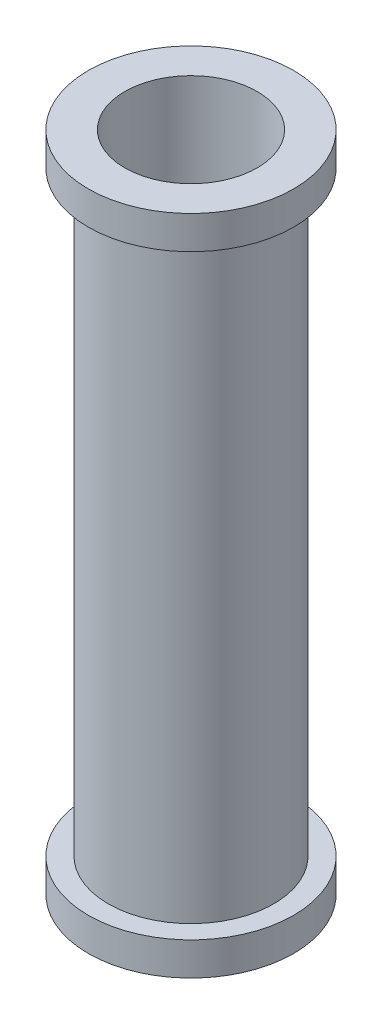
from build123d import *

# Parameters (mm, degrees)
SKETCH3_R   = 0.25
SKETCH3_R_2 = 0.2
SKETCH6_R   = 0.31
SKETCH6_R_2 = 0.21


with BuildPart() as part:
    # Sweep-Thin1: sweep along a path in Sketch1
    with BuildLine(Plane.XY) as sweep_thin1_path:
        Line((0, 0), (0, 1))
    # Sketch3 → Sweep-Thin1 (sweep)
    with BuildSketch(Plane(origin=(0, 0, 0), x_dir=(1, 0, 0), z_dir=(0, 1, 0))):
        Circle(SKETCH3_R)
        Circle(SKETCH3_R_2, mode=Mode.SUBTRACT)
    sweep(path=sweep_thin1_path.line)

    # Sweep-Thin2: sweep along a path in Sketch5
    with BuildLine(Plane.XY) as sweep_thin2_path:
        Line((0, 0), (0, 0.1))
    # Sketch6 → Sweep-Thin2 (sweep)
    with BuildSketch(Plane(origin=(0, 0, 0), x_dir=(1, 0, 0), z_dir=(0, 1, 0))):
        Circle(SKETCH6_R)
        Circle(SKETCH6_R_2, mode=Mode.SUBTRACT)
    sweep(path=sweep_thin2_path.line)

    # Mirror2: part across plane


with BuildPart() as part_1:
    add(part.part)
    add(part.part.mirror(Plane.ZX.offset(1)))


solid = part_1.part
